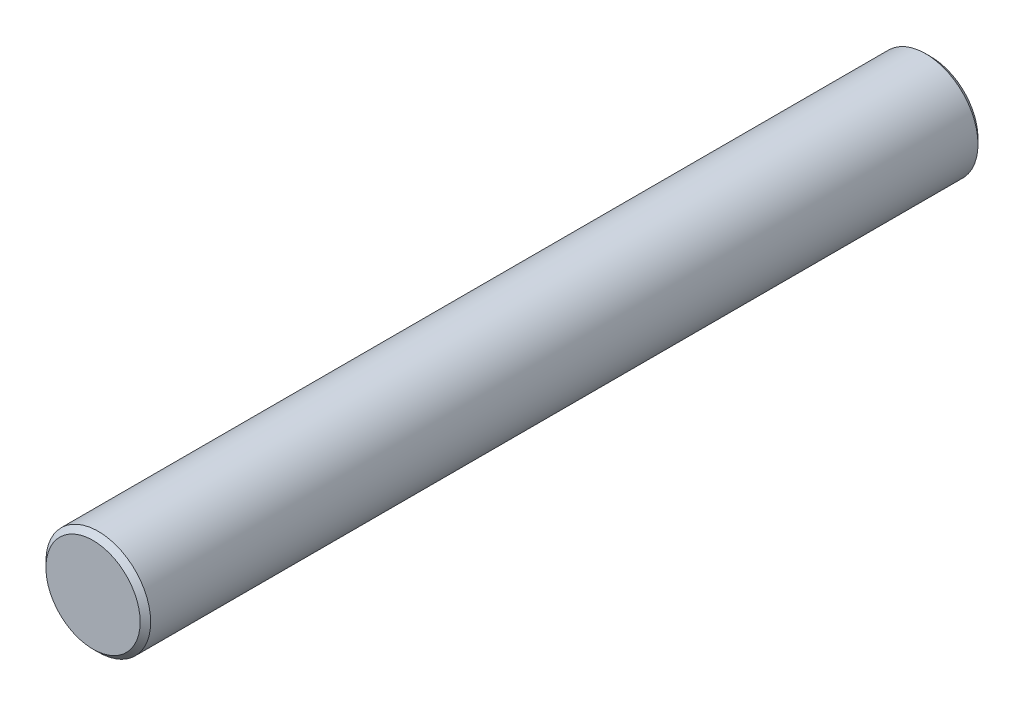
from build123d import *

# Parameters (mm, degrees)
SKETCH2_R           = 1.5
BOSS_EXTRUDE1_DEPTH = 24
CHAMFER1_SIZE       = 0.15


with BuildPart() as part:
    # Sketch2 → Boss-Extrude1 (new body)
    with BuildSketch(Plane.XY):
        Circle(SKETCH2_R)
    extrude(amount=BOSS_EXTRUDE1_DEPTH)

    # Chamfer1
    chamfer1_edges = [part.edges().sort_by_distance(p)[0] for p in [
        (-1.5, 0, 0),
        (-1.5, 0, 24),
    ]]
    chamfer(chamfer1_edges, length=CHAMFER1_SIZE)


solid = part.part
